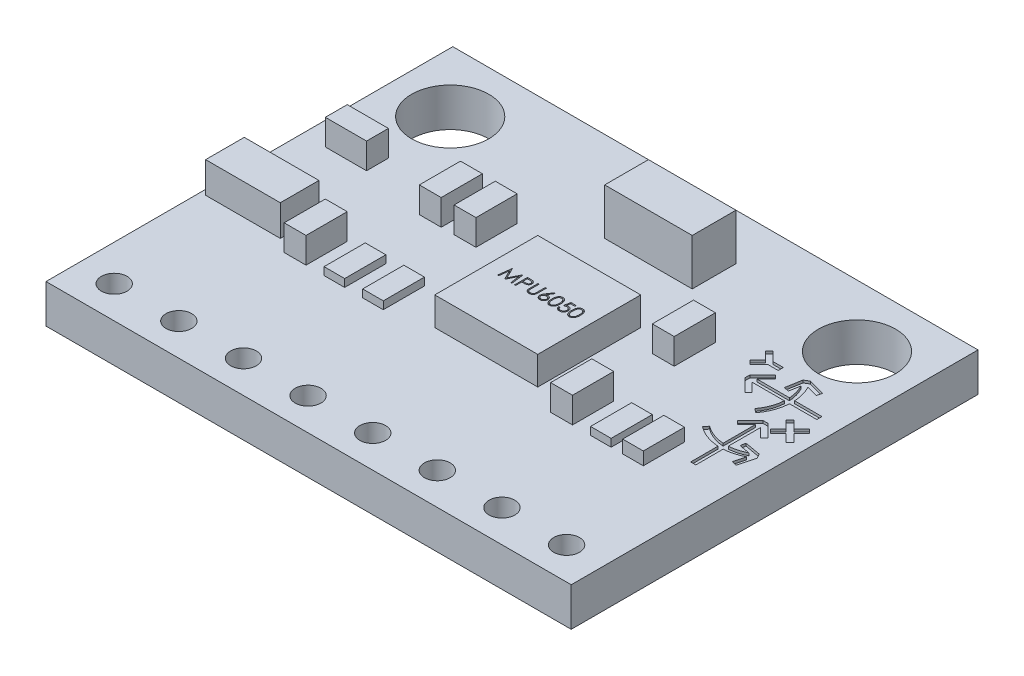
from build123d import *

# Parameters (mm, degrees)
SKETCH1_W           = 20.4
SKETCH1_H           = 15.8
BOSS_EXTRUDE1_DEPTH = 1.5
CUT_EXTRUDE1_REACH  = 3.5
SKETCH2_R           = 1.5
CUT_EXTRUDE2_REACH  = 3.5
SKETCH3_R           = 0.5
SKETCH4_W           = 3.4
SKETCH4_H           = 1.7
BOSS_EXTRUDE2_DEPTH = 1.8
SKETCH5_W           = 4
SKETCH5_H           = 4
BOSS_EXTRUDE3_DEPTH = 1.1
CUT_EXTRUDE3_DEPTH  = 0.1
SKETCH6_W           = 2.9
SKETCH6_H           = 1.5
BOSS_EXTRUDE4_DEPTH = 1.2
SKETCH7_W           = 0.85
SKETCH7_H           = 1.6
SKETCH7_W_2         = 1.6
SKETCH7_H_2         = 0.85
BOSS_EXTRUDE5_DEPTH = 1
SKETCH8_W           = 0.8
SKETCH8_H           = 1.6
BOSS_EXTRUDE6_DEPTH = 0.3
SKETCH10_W          = 0.8
SKETCH10_H          = 1.6
BOSS_EXTRUDE8_DEPTH = 0.5
CUT_EXTRUDE4_DEPTH  = 0.1
SKETCH13_R          = 1
BOSS_EXTRUDE9_DEPTH = 1


with BuildPart() as part:
    # Sketch1 → Boss-Extrude1 (new body)
    with BuildSketch(Plane(origin=(0, 0, 0), x_dir=(1, 0, 0), z_dir=(0, 1, 0))):
        Rectangle(SKETCH1_W, SKETCH1_H)
    extrude(amount=BOSS_EXTRUDE1_DEPTH)

    # Sketch2 → Cut-Extrude1 (cut, up to next)
    with BuildSketch(Plane(origin=(0, 1.5, 0), x_dir=(1, 0, 0), z_dir=(0, 1, 0)), mode=Mode.PRIVATE) as cut_extrude1_sk1:
        with Locations((-7.9, 5.5)):
            Circle(SKETCH2_R)
    cut_extrude1_tool1 = extrude(cut_extrude1_sk1.sketch, amount=-CUT_EXTRUDE1_REACH, mode=Mode.PRIVATE) & part.part
    add(cut_extrude1_tool1.solids().sort_by_distance((-7.9, 1.5, -5.5))[0], mode=Mode.SUBTRACT)
    # Sketch2 → Cut-Extrude1 (cut, up to next)
    with BuildSketch(Plane(origin=(0, 1.5, 0), x_dir=(1, 0, 0), z_dir=(0, 1, 0)), mode=Mode.PRIVATE) as cut_extrude1_sk2:
        with Locations((7.9, 5.5)):
            Circle(SKETCH2_R)
    cut_extrude1_tool2 = extrude(cut_extrude1_sk2.sketch, amount=-CUT_EXTRUDE1_REACH, mode=Mode.PRIVATE) & part.part
    add(cut_extrude1_tool2.solids().sort_by_distance((7.9, 1.5, -5.5))[0], mode=Mode.SUBTRACT)

    # Sketch3 → Cut-Extrude2 (cut, up to next)
    with BuildSketch(Plane(origin=(0, 1.5, 0), x_dir=(1, 0, 0), z_dir=(0, 1, 0)), mode=Mode.PRIVATE) as cut_extrude2_sk1:
        with Locations((-8.8, -6.65)):
            Circle(SKETCH3_R)
    cut_extrude2_tool1 = extrude(cut_extrude2_sk1.sketch, amount=-CUT_EXTRUDE2_REACH, mode=Mode.PRIVATE) & part.part
    add(cut_extrude2_tool1.solids().sort_by_distance((-8.8, 1.5, 6.65))[0], mode=Mode.SUBTRACT)
    # Sketch3 → Cut-Extrude2 (cut, up to next)
    with BuildSketch(Plane(origin=(0, 1.5, 0), x_dir=(1, 0, 0), z_dir=(0, 1, 0)), mode=Mode.PRIVATE) as cut_extrude2_sk2:
        with Locations((-6.29, -6.65)):
            Circle(SKETCH3_R)
    cut_extrude2_tool2 = extrude(cut_extrude2_sk2.sketch, amount=-CUT_EXTRUDE2_REACH, mode=Mode.PRIVATE) & part.part
    add(cut_extrude2_tool2.solids().sort_by_distance((-6.29, 1.5, 6.65))[0], mode=Mode.SUBTRACT)
    # Sketch3 → Cut-Extrude2 (cut, up to next)
    with BuildSketch(Plane(origin=(0, 1.5, 0), x_dir=(1, 0, 0), z_dir=(0, 1, 0)), mode=Mode.PRIVATE) as cut_extrude2_sk3:
        with Locations((-3.78, -6.65)):
            Circle(SKETCH3_R)
    cut_extrude2_tool3 = extrude(cut_extrude2_sk3.sketch, amount=-CUT_EXTRUDE2_REACH, mode=Mode.PRIVATE) & part.part
    add(cut_extrude2_tool3.solids().sort_by_distance((-3.78, 1.5, 6.65))[0], mode=Mode.SUBTRACT)
    # Sketch3 → Cut-Extrude2 (cut, up to next)
    with BuildSketch(Plane(origin=(0, 1.5, 0), x_dir=(1, 0, 0), z_dir=(0, 1, 0)), mode=Mode.PRIVATE) as cut_extrude2_sk4:
        with Locations((-1.27, -6.65)):
            Circle(SKETCH3_R)
    cut_extrude2_tool4 = extrude(cut_extrude2_sk4.sketch, amount=-CUT_EXTRUDE2_REACH, mode=Mode.PRIVATE) & part.part
    add(cut_extrude2_tool4.solids().sort_by_distance((-1.27, 1.5, 6.65))[0], mode=Mode.SUBTRACT)
    # Sketch3 → Cut-Extrude2 (cut, up to next)
    with BuildSketch(Plane(origin=(0, 1.5, 0), x_dir=(1, 0, 0), z_dir=(0, 1, 0)), mode=Mode.PRIVATE) as cut_extrude2_sk5:
        with Locations((1.24, -6.65)):
            Circle(SKETCH3_R)
    cut_extrude2_tool5 = extrude(cut_extrude2_sk5.sketch, amount=-CUT_EXTRUDE2_REACH, mode=Mode.PRIVATE) & part.part
    add(cut_extrude2_tool5.solids().sort_by_distance((1.24, 1.5, 6.65))[0], mode=Mode.SUBTRACT)
    # Sketch3 → Cut-Extrude2 (cut, up to next)
    with BuildSketch(Plane(origin=(0, 1.5, 0), x_dir=(1, 0, 0), z_dir=(0, 1, 0)), mode=Mode.PRIVATE) as cut_extrude2_sk6:
        with Locations((3.75, -6.65)):
            Circle(SKETCH3_R)
    cut_extrude2_tool6 = extrude(cut_extrude2_sk6.sketch, amount=-CUT_EXTRUDE2_REACH, mode=Mode.PRIVATE) & part.part
    add(cut_extrude2_tool6.solids().sort_by_distance((3.75, 1.5, 6.65))[0], mode=Mode.SUBTRACT)
    # Sketch3 → Cut-Extrude2 (cut, up to next)
    with BuildSketch(Plane(origin=(0, 1.5, 0), x_dir=(1, 0, 0), z_dir=(0, 1, 0)), mode=Mode.PRIVATE) as cut_extrude2_sk7:
        with Locations((6.26, -6.65)):
            Circle(SKETCH3_R)
    cut_extrude2_tool7 = extrude(cut_extrude2_sk7.sketch, amount=-CUT_EXTRUDE2_REACH, mode=Mode.PRIVATE) & part.part
    add(cut_extrude2_tool7.solids().sort_by_distance((6.26, 1.5, 6.65))[0], mode=Mode.SUBTRACT)
    # Sketch3 → Cut-Extrude2 (cut, up to next)
    with BuildSketch(Plane(origin=(0, 1.5, 0), x_dir=(1, 0, 0), z_dir=(0, 1, 0)), mode=Mode.PRIVATE) as cut_extrude2_sk8:
        with Locations((8.77, -6.65)):
            Circle(SKETCH3_R)
    cut_extrude2_tool8 = extrude(cut_extrude2_sk8.sketch, amount=-CUT_EXTRUDE2_REACH, mode=Mode.PRIVATE) & part.part
    add(cut_extrude2_tool8.solids().sort_by_distance((8.77, 1.5, 6.65))[0], mode=Mode.SUBTRACT)

    # Sketch4 → Boss-Extrude2 (add)
    with BuildSketch(Plane(origin=(0, 1.5, 0), x_dir=(1, 0, 0), z_dir=(0, 1, 0))):
        with Locations((0.9, 5.25)):
            Rectangle(SKETCH4_W, SKETCH4_H)
    extrude(amount=BOSS_EXTRUDE2_DEPTH)

    # Sketch5 → Boss-Extrude3 (add)
    with BuildSketch(Plane(origin=(0, 1.5, 0), x_dir=(1, 0, 0), z_dir=(0, 1, 0))):
        with Locations((0.9, 0.1)):
            Rectangle(SKETCH5_W, SKETCH5_H)
    extrude(amount=BOSS_EXTRUDE3_DEPTH)

    # Sketch11 → Cut-Extrude3 (cut)
    with BuildSketch(Plane(origin=(0, 2.6, 0), x_dir=(1, 0, 0), z_dir=(0, 1, 0))):
        Polygon((-0.549218035, -0.010882955), (-0.483212426, 0.489117045), (-0.47680217, 0.489117045), (-0.270371881, 0.078860635), (-0.064442394, 0.489117045), (-0.057931977, 0.489117045), (0.008474273, -0.010882955), (-0.036597843, -0.010882955), (-0.084474445, 0.348892686), (-0.264963227, -0.010882955), (-0.275079413, -0.010882955), (-0.456269317, 0.349693968), (-0.504045759, -0.010882955), align=None)
        with BuildLine():
            Line((0.111038375, 0.489117045), (0.209095266, 0.489117045))
            add(Edge.make_bspline(
                [(0.209095266, 0.489117045), (0.215839681, 0.489109631), (0.22876228, 0.489095426), (0.247293003, 0.488664748), (0.264122964, 0.488089506), (0.279215876, 0.487292093), (0.292618175, 0.486349723), (0.304269218, 0.485028003), (0.314260583, 0.483647961), (0.320247219, 0.482244903), (0.322977478, 0.481605026)],
                knots=[0, 0, 0, 0, 2.0233e-05, 3.8767e-05, 5.5604e-05, 7.075e-05, 8.4109e-05, 9.5899e-05, 0.000105928, 0.000114337, 0.000114337, 0.000114337, 0.000114337], degree=3))
            add(Edge.make_bspline(
                [(0.322977478, 0.481605026), (0.326433697, 0.480659033), (0.333264694, 0.478789338), (0.3431077, 0.475044521), (0.352472535, 0.470604211), (0.361391329, 0.465543649), (0.369754484, 0.459645711), (0.377686775, 0.45314948), (0.385118201, 0.44590497), (0.392006971, 0.437993436), (0.398333371, 0.429547691), (0.403780468, 0.420441659), (0.408341501, 0.410828615), (0.412253397, 0.400715248), (0.41506889, 0.39001663), (0.417189876, 0.3788071), (0.418536108, 0.367087858), (0.418665046, 0.359079306), (0.418730683, 0.355002462)],
                knots=[0, 0, 0, 0, 1.0745e-05, 2.1237e-05, 3.1542e-05, 4.1816e-05, 5.1958e-05, 6.2205e-05, 7.2546e-05, 8.3052e-05, 9.3649e-05, 0.000104162, 0.000114824, 0.000125539, 0.000136642, 0.000147957, 0.000159748, 0.000171974, 0.000171974, 0.000171974, 0.000171974], degree=3))
            add(Edge.make_bspline(
                [(0.418730683, 0.355002462), (0.418670479, 0.350891351), (0.418552687, 0.342847684), (0.417138932, 0.331080143), (0.415234619, 0.319834659), (0.412306469, 0.309136166), (0.408471372, 0.299048199), (0.403972508, 0.289416594), (0.398546289, 0.280405212), (0.392311313, 0.271981339), (0.385375371, 0.264137065), (0.377767809, 0.256929238), (0.369519338, 0.250400046), (0.360656174, 0.244534854), (0.35109191, 0.239469672), (0.340971603, 0.234932914), (0.330207286, 0.231122762), (0.322758355, 0.229118468), (0.318971067, 0.228099417)],
                knots=[0, 0, 0, 0, 1.2326e-05, 2.4117e-05, 3.5512e-05, 4.652e-05, 5.7328e-05, 6.7857e-05, 7.8369e-05, 8.8826e-05, 9.9257e-05, 0.000109743, 0.000120223, 0.00013078, 0.000141579, 0.000152654, 0.000164027, 0.00017579, 0.00017579, 0.00017579, 0.00017579], degree=3))
            add(Edge.make_bspline(
                [(0.318971067, 0.228099417), (0.315838591, 0.227433277), (0.308973587, 0.225973392), (0.297667484, 0.224343612), (0.284503858, 0.222952526), (0.269500675, 0.221909507), (0.252671403, 0.221016597), (0.234006937, 0.220306869), (0.21347064, 0.21991689), (0.199146177, 0.219896777), (0.191667382, 0.219886276)],
                knots=[0, 0, 0, 0, 9.605e-06, 2.1051e-05, 3.4247e-05, 4.9311e-05, 6.6162e-05, 8.4805e-05, 0.000105342, 0.000127778, 0.000127778, 0.000127778, 0.000127778], degree=3))
            Line((0.191667382, 0.219886276), (0.15591017, 0.219886276))
            Line((0.15591017, 0.219886276), (0.15591017, -0.010882955))
            Line((0.15591017, -0.010882955), (0.111038375, -0.010882955))
            Line((0.111038375, -0.010882955), (0.111038375, 0.489117045))
        make_face()
        with BuildLine():
            Line((0.15591017, 0.437834994), (0.15591017, 0.271168327))
            Line((0.15591017, 0.271168327), (0.243450234, 0.270066564))
            add(Edge.make_bspline(
                [(0.243450234, 0.270066564), (0.247724509, 0.270064355), (0.255975909, 0.27006009), (0.26789537, 0.270629408), (0.278953839, 0.271286627), (0.28911735, 0.272248902), (0.298390484, 0.273609082), (0.306788702, 0.274982187), (0.314246885, 0.276968667), (0.322975343, 0.279643391), (0.332701535, 0.284205194), (0.343282613, 0.290826607), (0.35224984, 0.299266708), (0.360009597, 0.308756398), (0.366167579, 0.319313416), (0.370675578, 0.330608979), (0.373324315, 0.342527243), (0.373679486, 0.350682691), (0.373858888, 0.354802141)],
                knots=[0, 0, 0, 0, 1.2821e-05, 2.475e-05, 3.579e-05, 4.6056e-05, 5.5362e-05, 6.3909e-05, 7.1561e-05, 7.8498e-05, 9.1272e-05, 0.000103663, 0.000115784, 0.000128032, 0.000140332, 0.000152291, 0.000164394, 0.000176747, 0.000176747, 0.000176747, 0.000176747], degree=3))
            add(Edge.make_bspline(
                [(0.373858888, 0.354802141), (0.37367851, 0.358821929), (0.373319941, 0.366812769), (0.370654817, 0.378524021), (0.366176344, 0.38970055), (0.359968259, 0.400125276), (0.352433812, 0.40958082), (0.343676763, 0.417794695), (0.333717725, 0.424397795), (0.324453692, 0.428659693), (0.316224952, 0.431261875), (0.309077529, 0.433082566), (0.301007432, 0.434536224), (0.292012035, 0.435713296), (0.282161059, 0.436720934), (0.271369871, 0.437404645), (0.259679351, 0.437804853), (0.251563555, 0.437824703), (0.247356484, 0.437834994)],
                knots=[0, 0, 0, 0, 1.2053e-05, 2.396e-05, 3.5826e-05, 4.804e-05, 6.0225e-05, 7.1989e-05, 8.3907e-05, 9.5918e-05, 0.000102443, 0.00010978, 0.00011803, 0.000127025, 0.000136992, 0.000147732, 0.000159457, 0.000172078, 0.000172078, 0.000172078, 0.000172078], degree=3))
            Line((0.247356484, 0.437834994), (0.15591017, 0.437834994))
        make_face(mode=Mode.SUBTRACT)
        with BuildLine():
            Line((0.521294785, 0.489117045), (0.56616658, 0.489117045))
            Line((0.56616658, 0.489117045), (0.56616658, 0.189537718))
            add(Edge.make_bspline(
                [(0.56616658, 0.189537718), (0.566159903, 0.185297613), (0.56614723, 0.177251283), (0.566231875, 0.165798668), (0.566468928, 0.155616889), (0.566618379, 0.146666696), (0.566950855, 0.138989161), (0.567222005, 0.132542688), (0.567570656, 0.127357802), (0.567989673, 0.124331955), (0.568169785, 0.123031308)],
                knots=[0, 0, 0, 0, 1.272e-05, 2.4139e-05, 3.4357e-05, 4.3274e-05, 5.0992e-05, 5.7409e-05, 6.2633e-05, 6.6571e-05, 6.6571e-05, 6.6571e-05, 6.6571e-05], degree=3))
            add(Edge.make_bspline(
                [(0.568169785, 0.123031308), (0.568909422, 0.118338913), (0.57034702, 0.109218523), (0.574010789, 0.096231626), (0.579127575, 0.084527132), (0.585190866, 0.073739804), (0.593181239, 0.064169896), (0.602753173, 0.055353945), (0.614349997, 0.047643688), (0.627244369, 0.040593572), (0.64114226, 0.034927131), (0.65534387, 0.030642365), (0.669635724, 0.028031094), (0.679203748, 0.027728731), (0.683955042, 0.027578583)],
                knots=[0, 0, 0, 0, 1.4244e-05, 2.7686e-05, 4.0338e-05, 5.2501e-05, 6.4671e-05, 7.7574e-05, 9.1409e-05, 0.000106333, 0.000121604, 0.00013634, 0.000150781, 0.000165026, 0.000165026, 0.000165026, 0.000165026], degree=3))
            add(Edge.make_bspline(
                [(0.683955042, 0.027578583), (0.688034148, 0.027731991), (0.696168799, 0.028037919), (0.708255432, 0.029932409), (0.720026876, 0.033346776), (0.731541259, 0.037752455), (0.742334257, 0.04357354), (0.752411891, 0.050297945), (0.761406739, 0.058185213), (0.769615025, 0.066913834), (0.776762873, 0.076762377), (0.78295875, 0.087516397), (0.788033883, 0.099337732), (0.790540101, 0.107645507), (0.791827638, 0.111913519)],
                knots=[0, 0, 0, 0, 1.224e-05, 2.4409e-05, 3.6585e-05, 4.8953e-05, 6.132e-05, 7.3294e-05, 8.5222e-05, 9.7128e-05, 0.000109168, 0.000121641, 0.000134293, 0.00014766, 0.00014766, 0.00014766, 0.00014766], degree=3))
            add(Edge.make_bspline(
                [(0.791827638, 0.111913519), (0.792256227, 0.113677601), (0.793211297, 0.117608687), (0.794103732, 0.124254586), (0.795033236, 0.132095923), (0.795678174, 0.14118904), (0.79630692, 0.151503464), (0.796683073, 0.16309293), (0.796856935, 0.175915353), (0.796908747, 0.184863518), (0.796935811, 0.189537718)],
                knots=[0, 0, 0, 0, 5.443e-06, 1.2129e-05, 2.0093e-05, 2.9134e-05, 3.9468e-05, 5.1094e-05, 6.3916e-05, 7.7939e-05, 7.7939e-05, 7.7939e-05, 7.7939e-05], degree=3))
            Line((0.796935811, 0.189537718), (0.796935811, 0.489117045))
            Line((0.796935811, 0.489117045), (0.841807606, 0.489117045))
            Line((0.841807606, 0.489117045), (0.841807606, 0.187133872))
            add(Edge.make_bspline(
                [(0.841807606, 0.187133872), (0.841771303, 0.181691246), (0.841700456, 0.171069632), (0.841086088, 0.155505152), (0.840106516, 0.14074044), (0.838722504, 0.126773512), (0.836888646, 0.113654346), (0.834849329, 0.101267951), (0.832252253, 0.089703238), (0.82921891, 0.078870035), (0.82575126, 0.068557819), (0.821259667, 0.058770874), (0.816199024, 0.049211674), (0.810196931, 0.040024801), (0.803452448, 0.03116958), (0.795816494, 0.022699712), (0.787541613, 0.014479848), (0.778490248, 0.006720838), (0.768811601, -0.000394687), (0.758534464, -0.006651511), (0.747737783, -0.011940599), (0.736449622, -0.016294303), (0.724665165, -0.019567817), (0.712384113, -0.022007125), (0.699578514, -0.023393168), (0.690869278, -0.023599158), (0.686459048, -0.023703468)],
                knots=[0, 0, 0, 0, 1.6327e-05, 3.1864e-05, 4.6721e-05, 6.0714e-05, 7.3958e-05, 8.6456e-05, 9.8363e-05, 0.000109494, 0.0001202, 0.00013096, 0.000141759, 0.000152622, 0.00016384, 0.000175119, 0.000186806, 0.00019881, 0.00021085, 0.000222806, 0.000234856, 0.000246872, 0.000259048, 0.000271502, 0.000284399, 0.000297629, 0.000297629, 0.000297629, 0.000297629], degree=3))
            add(Edge.make_bspline(
                [(0.686459048, -0.023703468), (0.681649176, -0.023591359), (0.672212225, -0.0233714), (0.658306787, -0.022111008), (0.644976187, -0.019736951), (0.632079634, -0.016714102), (0.619792705, -0.012544997), (0.607950785, -0.007673836), (0.596756688, -0.00169137), (0.586028812, 0.004964829), (0.576053847, 0.012454063), (0.566897075, 0.020616945), (0.558543379, 0.029322713), (0.551133565, 0.038665622), (0.544544868, 0.048573009), (0.538869123, 0.0590729), (0.533995802, 0.070161231), (0.531480578, 0.077868831), (0.530209048, 0.081765282)],
                knots=[0, 0, 0, 0, 1.4432e-05, 2.8315e-05, 4.1834e-05, 5.5025e-05, 6.8011e-05, 8.0716e-05, 9.3396e-05, 0.00010604, 0.00011856, 0.000130763, 0.000142806, 0.00015471, 0.000166489, 0.000178455, 0.000190476, 0.000202766, 0.000202766, 0.000202766, 0.000202766], degree=3))
            add(Edge.make_bspline(
                [(0.530209048, 0.081765282), (0.529469454, 0.084427078), (0.527865258, 0.090200574), (0.526147359, 0.099755787), (0.524703204, 0.110757918), (0.523345267, 0.12320772), (0.522543987, 0.137114844), (0.521841496, 0.152473261), (0.521289836, 0.169301541), (0.52129309, 0.181023615), (0.521294785, 0.187133872)],
                knots=[0, 0, 0, 0, 8.284e-06, 1.7969e-05, 2.9088e-05, 4.1576e-05, 5.5528e-05, 7.0868e-05, 8.7703e-05, 0.000106032, 0.000106032, 0.000106032, 0.000106032], degree=3))
            Line((0.521294785, 0.187133872), (0.521294785, 0.489117045))
        make_face()
        with BuildLine():
            Line((1.15591017, 0.501937558), (1.190465458, 0.474794128))
            Line((1.190465458, 0.474794128), (1.05835408, 0.272770891))
            add(Edge.make_bspline(
                [(1.05835408, 0.272770891), (1.067149834, 0.274172871), (1.084306946, 0.276907592), (1.101673503, 0.277358727), (1.110136933, 0.277578583)],
                knots=[0, 0, 0, 0, 2.6687e-05, 5.2056e-05, 5.2056e-05, 5.2056e-05, 5.2056e-05], degree=3))
            add(Edge.make_bspline(
                [(1.110136933, 0.277578583), (1.115218718, 0.277441996), (1.125222061, 0.277173128), (1.139908747, 0.275104006), (1.154021452, 0.271843276), (1.167501682, 0.267090097), (1.180397823, 0.261018332), (1.192783879, 0.25374135), (1.204427024, 0.244883396), (1.215477192, 0.234988402), (1.225509635, 0.224028833), (1.234391928, 0.212400071), (1.241852898, 0.20011423), (1.247906316, 0.187177535), (1.252607013, 0.173609927), (1.256033819, 0.159428764), (1.258059475, 0.144624268), (1.258334545, 0.134555957), (1.258474273, 0.129441564)],
                knots=[0, 0, 0, 0, 1.524e-05, 3e-05, 4.4407e-05, 5.863e-05, 7.2789e-05, 8.7115e-05, 0.000101639, 0.000116603, 0.00013156, 0.000146144, 0.000160436, 0.000174595, 0.000188912, 0.00020344, 0.000218299, 0.00023364, 0.00023364, 0.00023364, 0.00023364], degree=3))
            add(Edge.make_bspline(
                [(1.258474273, 0.129441564), (1.258270972, 0.122444464), (1.257870924, 0.108675826), (1.253884668, 0.08862201), (1.247690433, 0.069517365), (1.2388365, 0.051666912), (1.227839017, 0.035095117), (1.214427932, 0.020411479), (1.199078862, 0.007315759), (1.181723605, -0.003635187), (1.163046039, -0.01257848), (1.143424325, -0.019002086), (1.123049019, -0.022956867), (1.109219789, -0.023452667), (1.102224273, -0.023703468)],
                knots=[0, 0, 0, 0, 2.0968e-05, 4.126e-05, 6.1088e-05, 8.1066e-05, 0.000100845, 0.000120559, 0.000140527, 0.000161199, 0.000181942, 0.000202498, 0.000222987, 0.000243961, 0.000243961, 0.000243961, 0.000243961], degree=3))
            add(Edge.make_bspline(
                [(1.102224273, -0.023703468), (1.095496172, -0.023485153), (1.082168984, -0.023052709), (1.062564299, -0.019200432), (1.043726725, -0.01295656), (1.025788242, -0.00435452), (1.009171012, 0.006510892), (0.994304492, 0.019591217), (0.98126281, 0.034606855), (0.970409293, 0.051555476), (0.961800903, 0.069768327), (0.955345199, 0.088759349), (0.951574307, 0.108459347), (0.951047371, 0.121813795), (0.950781965, 0.128540122)],
                knots=[0, 0, 0, 0, 2.0168e-05, 3.9949e-05, 5.9682e-05, 7.9573e-05, 9.9463e-05, 0.000119052, 0.000138792, 0.000158934, 0.00017923, 0.000199089, 0.000218969, 0.000239143, 0.000239143, 0.000239143, 0.000239143], degree=3))
            add(Edge.make_bspline(
                [(0.950781965, 0.128540122), (0.950950743, 0.133689348), (0.951295355, 0.144203084), (0.953701553, 0.160126517), (0.957567953, 0.176419528), (0.961897988, 0.190241556), (0.966473075, 0.20156463), (0.970280581, 0.210693701), (0.975019723, 0.22008814), (0.980073063, 0.230070088), (0.985895473, 0.240382292), (0.99222628, 0.251197102), (0.999240516, 0.26234252), (1.004157682, 0.269905977), (1.006671388, 0.273772494)],
                knots=[0, 0, 0, 0, 1.5445e-05, 3.1537e-05, 4.8203e-05, 6.5657e-05, 7.4919e-05, 8.4835e-05, 9.5317e-05, 0.000106472, 0.000118399, 0.000130836, 0.000144064, 0.0001579, 0.0001579, 0.0001579, 0.0001579], degree=3))
            Line((1.006671388, 0.273772494), (1.15591017, 0.501937558))
        make_face()
        with BuildLine():
            add(Edge.make_bspline(
                [(1.100721869, 0.226296532), (1.096912977, 0.226185383), (1.089473104, 0.225968277), (1.078557759, 0.224707526), (1.068227294, 0.222333374), (1.058344847, 0.219309612), (1.049095175, 0.215152032), (1.040411055, 0.210101775), (1.032258905, 0.204155893), (1.024724112, 0.19739862), (1.017892731, 0.190000329), (1.012009712, 0.182076112), (1.006935084, 0.17381694), (1.00280911, 0.165153805), (0.999596242, 0.15609002), (0.997272206, 0.14666727), (0.995978813, 0.136822369), (0.995763637, 0.130146297), (0.99565376, 0.126737237)],
                knots=[0, 0, 0, 0, 1.1429e-05, 2.2325e-05, 3.2895e-05, 4.319e-05, 5.3279e-05, 6.3243e-05, 7.328e-05, 8.3494e-05, 9.356e-05, 0.000103436, 0.000113055, 0.000122598, 0.000132165, 0.000141858, 0.00015166, 0.000161889, 0.000161889, 0.000161889, 0.000161889], degree=3))
            add(Edge.make_bspline(
                [(0.99565376, 0.126737237), (0.99574324, 0.123358669), (0.995918697, 0.116733799), (0.997511886, 0.106971059), (0.999945469, 0.097576072), (1.003565526, 0.088597272), (1.007883652, 0.079897798), (1.013584413, 0.071792757), (1.019901097, 0.06378989), (1.027451659, 0.056503966), (1.035554996, 0.049724448), (1.044212311, 0.043798697), (1.053235162, 0.038729244), (1.062745365, 0.03475623), (1.072607992, 0.031495618), (1.082905214, 0.029201121), (1.093644193, 0.027903903), (1.100918756, 0.027688446), (1.104628119, 0.027578583)],
                knots=[0, 0, 0, 0, 1.0129e-05, 1.9861e-05, 2.9603e-05, 3.9182e-05, 4.8857e-05, 5.8664e-05, 6.8847e-05, 7.94e-05, 9.007e-05, 0.000100516, 0.000110828, 0.00012106, 0.000131386, 0.000141957, 0.000152653, 0.000163782, 0.000163782, 0.000163782, 0.000163782], degree=3))
            add(Edge.make_bspline(
                [(1.104628119, 0.027578583), (1.108337476, 0.027688455), (1.115612026, 0.027903928), (1.126351092, 0.029201024), (1.136647995, 0.031495973), (1.146511782, 0.034754941), (1.1560177, 0.038734028), (1.165032661, 0.043767159), (1.173608103, 0.04976089), (1.18171676, 0.05649238), (1.189235894, 0.063831359), (1.195704076, 0.071721319), (1.201230253, 0.079963304), (1.205720851, 0.088563003), (1.209301035, 0.097581501), (1.211746959, 0.106969604), (1.213336857, 0.116734179), (1.213512767, 0.123358797), (1.213602478, 0.126737237)],
                knots=[0, 0, 0, 0, 1.1129e-05, 2.1826e-05, 3.2396e-05, 4.2722e-05, 5.2954e-05, 6.3266e-05, 7.363e-05, 8.4299e-05, 9.4852e-05, 0.000105099, 0.00011485, 0.000124572, 0.00013415, 0.000143893, 0.000153625, 0.000163753, 0.000163753, 0.000163753, 0.000163753], degree=3))
            add(Edge.make_bspline(
                [(1.213602478, 0.126737237), (1.213523864, 0.130150745), (1.213369572, 0.136850349), (1.211624437, 0.146662866), (1.209204097, 0.156137896), (1.205549379, 0.165215888), (1.200801301, 0.173861021), (1.195017957, 0.182116964), (1.18832759, 0.190047013), (1.18059937, 0.197413129), (1.172186479, 0.204148426), (1.163241396, 0.210094077), (1.153883114, 0.21511193), (1.144121122, 0.219298659), (1.133843567, 0.222320013), (1.123216376, 0.224699047), (1.112103627, 0.22596505), (1.104564112, 0.226184631), (1.100721869, 0.226296532)],
                knots=[0, 0, 0, 0, 1.0229e-05, 2.0075e-05, 2.9818e-05, 3.9527e-05, 4.9343e-05, 5.9345e-05, 6.9721e-05, 8.0417e-05, 9.132e-05, 0.000102015, 0.000112591, 0.000123139, 0.000133816, 0.00014468, 0.000155775, 0.000167304, 0.000167304, 0.000167304, 0.000167304], degree=3))
        make_face(mode=Mode.SUBTRACT)
        with BuildLine():
            add(Edge.make_bspline(
                [(1.309756324, 0.238916724), (1.309803184, 0.246930637), (1.309894209, 0.262497778), (1.310906841, 0.285181298), (1.312589033, 0.306461339), (1.314894372, 0.32633892), (1.317699797, 0.344819172), (1.321444867, 0.361852709), (1.325703839, 0.377518367), (1.330639902, 0.391867231), (1.336209586, 0.405092617), (1.342271624, 0.417439074), (1.349066594, 0.428887922), (1.356206153, 0.439621892), (1.363979306, 0.449465277), (1.372164848, 0.458557086), (1.381082259, 0.466687193), (1.390428403, 0.474093808), (1.400287898, 0.480586589), (1.410379707, 0.486305552), (1.420773294, 0.491191247), (1.431497034, 0.495032738), (1.442454542, 0.498205716), (1.453684123, 0.500375566), (1.465204318, 0.501740839), (1.472980238, 0.501871363), (1.476923792, 0.501937558)],
                knots=[0, 0, 0, 0, 2.404e-05, 4.6699e-05, 6.8101e-05, 8.8066e-05, 0.000106723, 0.000124149, 0.000140356, 0.000155402, 0.000169633, 0.000183384, 0.000196628, 0.000209546, 0.000222029, 0.000234224, 0.000246203, 0.000258186, 0.000269964, 0.00028158, 0.000292962, 0.000304369, 0.000315719, 0.000327152, 0.000338644, 0.00035047, 0.00035047, 0.00035047, 0.00035047], degree=3))
            add(Edge.make_bspline(
                [(1.476923792, 0.501937558), (1.480900289, 0.50186787), (1.48880829, 0.501729283), (1.500499772, 0.500397291), (1.511921155, 0.49818713), (1.523023747, 0.495055563), (1.533898745, 0.491170466), (1.544461089, 0.486300878), (1.554776386, 0.480632468), (1.564680713, 0.473971914), (1.574282801, 0.466545875), (1.583346795, 0.458151208), (1.591873522, 0.448872676), (1.599969994, 0.438809553), (1.607406508, 0.427768827), (1.614488427, 0.415942525), (1.620827289, 0.40312383), (1.626932243, 0.389526621), (1.632201812, 0.374774669), (1.636954133, 0.358951132), (1.640793986, 0.341869105), (1.643992453, 0.323618213), (1.646470295, 0.30413143), (1.648274959, 0.283450528), (1.649228256, 0.2615619), (1.649407785, 0.246596493), (1.649499914, 0.238916724)],
                knots=[0, 0, 0, 0, 1.1926e-05, 2.3717e-05, 3.5247e-05, 4.6791e-05, 5.8292e-05, 6.9855e-05, 8.1646e-05, 9.3563e-05, 0.000105625, 0.000118029, 0.000130574, 0.000143401, 0.000156736, 0.000170478, 0.000184722, 0.000199611, 0.000215168, 0.000231679, 0.000249148, 0.000267657, 0.000287249, 0.00030806, 0.000329918, 0.000352958, 0.000352958, 0.000352958, 0.000352958], degree=3))
            add(Edge.make_bspline(
                [(1.649499914, 0.238916724), (1.64940683, 0.231270452), (1.649225461, 0.216372002), (1.648285645, 0.194581862), (1.646434412, 0.174010713), (1.6441187, 0.154609219), (1.640911419, 0.13645813), (1.636967824, 0.119494638), (1.632589207, 0.103645484), (1.627184236, 0.089040511), (1.62126842, 0.07547598), (1.614831964, 0.062809244), (1.607936274, 0.050928345), (1.600423596, 0.039928381), (1.592415966, 0.02973143), (1.583741996, 0.020517484), (1.574646198, 0.012064531), (1.565015853, 0.00454287), (1.55495706, -0.002040674), (1.544677192, -0.007928366), (1.533993851, -0.012675894), (1.523149144, -0.016752329), (1.511987949, -0.019866679), (1.500524179, -0.022020087), (1.488816145, -0.023530351), (1.480901636, -0.023645562), (1.476923792, -0.023703468)],
                knots=[0, 0, 0, 0, 2.294e-05, 4.4698e-05, 6.541e-05, 8.4889e-05, 0.0001033, 0.000120672, 0.000137126, 0.000152589, 0.000167346, 0.000181501, 0.000195192, 0.000208527, 0.000221432, 0.000234046, 0.00024645, 0.000258652, 0.000270653, 0.000282492, 0.000294147, 0.000305682, 0.000317226, 0.000328855, 0.000340657, 0.000352583, 0.000352583, 0.000352583, 0.000352583], degree=3))
            add(Edge.make_bspline(
                [(1.476923792, -0.023703468), (1.472980347, -0.023636846), (1.465204643, -0.02350548), (1.453682868, -0.022146375), (1.442499662, -0.019961303), (1.43159984, -0.016901788), (1.420927481, -0.013156812), (1.410628011, -0.008277714), (1.400586914, -0.002658561), (1.390830977, 0.003740784), (1.381543525, 0.011072453), (1.372672296, 0.019181638), (1.364440151, 0.028270696), (1.356778137, 0.038196114), (1.349496124, 0.048866577), (1.342797642, 0.060427773), (1.336601806, 0.07283386), (1.33093845, 0.086164991), (1.325917213, 0.100615695), (1.321481826, 0.116351291), (1.317979803, 0.133510668), (1.314982238, 0.151956006), (1.312564469, 0.171766568), (1.310913851, 0.192953107), (1.309893663, 0.215502423), (1.309802939, 0.230969534), (1.309756324, 0.238916724)],
                knots=[0, 0, 0, 0, 1.1826e-05, 2.3318e-05, 3.475e-05, 4.5977e-05, 5.7256e-05, 6.8638e-05, 8.0117e-05, 9.1757e-05, 0.000103599, 0.000115578, 0.000127773, 0.000140335, 0.00015317, 0.0001665, 0.000180386, 0.000194748, 0.000209921, 0.000226252, 0.000243755, 0.000262428, 0.000282305, 0.000303608, 0.000326166, 0.000350006, 0.000350006, 0.000350006, 0.000350006], degree=3))
        make_face()
        with BuildLine():
            add(Edge.make_bspline(
                [(1.354628119, 0.239117045), (1.354645183, 0.232438659), (1.3546783, 0.219477224), (1.355543472, 0.200642473), (1.356722076, 0.183075283), (1.358242262, 0.166753349), (1.360499826, 0.151731919), (1.363029367, 0.137907678), (1.366107665, 0.125353787), (1.369749811, 0.1139841), (1.373898253, 0.103605662), (1.378427662, 0.093948345), (1.38329348, 0.084898069), (1.388739073, 0.076536125), (1.394669796, 0.068835244), (1.40095169, 0.061659125), (1.407819202, 0.055259556), (1.417319737, 0.047584291), (1.42986209, 0.039652987), (1.445665013, 0.032746402), (1.461903363, 0.028406051), (1.47292497, 0.027854086), (1.478426196, 0.027578583)],
                knots=[0, 0, 0, 0, 2.0033e-05, 3.888e-05, 5.6549e-05, 7.2854e-05, 8.8039e-05, 0.000102104, 0.000115004, 0.000126787, 0.000137891, 0.00014851, 0.000158774, 0.000168692, 0.000178408, 0.000187915, 0.000197268, 0.000206529, 0.000224535, 0.00024158, 0.000258123, 0.000274609, 0.000274609, 0.000274609, 0.000274609], degree=3))
            add(Edge.make_bspline(
                [(1.478426196, 0.027578583), (1.483963006, 0.027806838), (1.495025195, 0.028262875), (1.511187166, 0.032662695), (1.526877204, 0.039301201), (1.539173196, 0.047150844), (1.548527845, 0.05462632), (1.555230272, 0.060999841), (1.561381993, 0.068136394), (1.567216575, 0.075836293), (1.572567872, 0.084246648), (1.577434034, 0.093327016), (1.581874513, 0.103102613), (1.584404376, 0.109926861), (1.58569783, 0.113415923)],
                knots=[0, 0, 0, 0, 1.6578e-05, 3.3121e-05, 4.9903e-05, 6.7548e-05, 7.6668e-05, 8.5806e-05, 9.5248e-05, 0.000104903, 0.000114767, 0.000125119, 0.000135787, 0.000146948, 0.000146948, 0.000146948, 0.000146948], degree=3))
            add(Edge.make_bspline(
                [(1.58569783, 0.113415923), (1.587205226, 0.117877314), (1.590265885, 0.126935852), (1.594210424, 0.140987803), (1.59731691, 0.155731055), (1.600111676, 0.1710775), (1.602019255, 0.187140314), (1.603554657, 0.203869798), (1.604459041, 0.221278564), (1.604571149, 0.23310642), (1.604628119, 0.239117045)],
                knots=[0, 0, 0, 0, 1.4127e-05, 2.8683e-05, 4.3751e-05, 5.9313e-05, 7.5463e-05, 9.2257e-05, 0.000109708, 0.00012774, 0.00012774, 0.00012774, 0.00012774], degree=3))
            add(Edge.make_bspline(
                [(1.604628119, 0.239117045), (1.60454952, 0.245126698), (1.604395765, 0.256882865), (1.603808052, 0.274099747), (1.602290399, 0.290452285), (1.60060481, 0.306010924), (1.598119493, 0.320689538), (1.595439806, 0.334611011), (1.591839633, 0.347602871), (1.587993951, 0.359868526), (1.583592466, 0.371268619), (1.578747361, 0.381856303), (1.573572824, 0.391682692), (1.567952504, 0.400720827), (1.561953121, 0.40901119), (1.555416328, 0.416387561), (1.548601418, 0.423078556), (1.539056105, 0.430716066), (1.526559778, 0.438503451), (1.5110104, 0.445669988), (1.494828879, 0.449785459), (1.483889815, 0.4503657), (1.478426196, 0.450655506)],
                knots=[0, 0, 0, 0, 1.8031e-05, 3.5273e-05, 5.1659e-05, 6.7289e-05, 8.2207e-05, 9.6311e-05, 0.000109795, 0.000122624, 0.000134863, 0.000146427, 0.000157539, 0.000168156, 0.000178333, 0.000188198, 0.000197689, 0.00020695, 0.000224818, 0.00024172, 0.000258142, 0.000274528, 0.000274528, 0.000274528, 0.000274528], degree=3))
            add(Edge.make_bspline(
                [(1.478426196, 0.450655506), (1.472896111, 0.4503653), (1.461825867, 0.449784358), (1.44547616, 0.445685322), (1.429804109, 0.438540612), (1.417340827, 0.430690273), (1.407788858, 0.423213372), (1.401062759, 0.416729592), (1.394756163, 0.40963727), (1.388946491, 0.401865568), (1.383505165, 0.393513373), (1.378507878, 0.384514978), (1.374005402, 0.374824783), (1.369850468, 0.364451007), (1.366197213, 0.3530823), (1.363183789, 0.340543873), (1.360399925, 0.326763602), (1.358429172, 0.311660815), (1.356677207, 0.295334794), (1.3555513, 0.277723748), (1.354675406, 0.258857408), (1.354644197, 0.245828957), (1.354628119, 0.239117045)],
                knots=[0, 0, 0, 0, 1.6586e-05, 3.3202e-05, 5.0195e-05, 6.8064e-05, 7.7262e-05, 8.6542e-05, 9.6049e-05, 0.000105705, 0.000115623, 0.000125935, 0.000136554, 0.000147658, 0.000159441, 0.000172341, 0.000186327, 0.000201596, 0.000218011, 0.00023558, 0.000254527, 0.000274661, 0.000274661, 0.000274661, 0.000274661], degree=3))
        make_face(mode=Mode.SUBTRACT)
        with BuildLine():
            Line((2.008474273, 0.489117045), (2.008474273, 0.437834994))
            Line((2.008474273, 0.437834994), (1.838402157, 0.437834994))
            Line((1.838402157, 0.437834994), (1.811459048, 0.306324577))
            add(Edge.make_bspline(
                [(1.811459048, 0.306324577), (1.816752745, 0.307786044), (1.827008444, 0.310617406), (1.842145567, 0.313761088), (1.856515882, 0.315656151), (1.865840935, 0.31591491), (1.870353279, 0.316040122)],
                knots=[0, 0, 0, 0, 1.6472e-05, 3.1911e-05, 4.6347e-05, 5.9882e-05, 5.9882e-05, 5.9882e-05, 5.9882e-05], degree=3))
            add(Edge.make_bspline(
                [(1.870353279, 0.316040122), (1.87593667, 0.315919274), (1.886915013, 0.315681657), (1.90297772, 0.313399964), (1.91831099, 0.309808547), (1.932882757, 0.30479133), (1.946719979, 0.298375654), (1.959695345, 0.290361377), (1.972003618, 0.280999472), (1.983423988, 0.270235899), (1.993784604, 0.258389954), (2.002894031, 0.245653115), (2.010631544, 0.232149163), (2.016854509, 0.217749076), (2.0218237, 0.202612055), (2.025131127, 0.186578828), (2.027333514, 0.169800526), (2.02757957, 0.158328444), (2.027705042, 0.152478423)],
                knots=[0, 0, 0, 0, 1.6741e-05, 3.2918e-05, 4.8563e-05, 6.3926e-05, 7.9071e-05, 9.4222e-05, 0.000109587, 0.000125389, 0.000141218, 0.000156727, 0.000172294, 0.000187813, 0.000203714, 0.000219999, 0.000236858, 0.0002544, 0.0002544, 0.0002544, 0.0002544], degree=3))
            add(Edge.make_bspline(
                [(2.027705042, 0.152478423), (2.027610031, 0.14840382), (2.027421294, 0.140309679), (2.026461495, 0.128289079), (2.024613536, 0.11652296), (2.022132432, 0.105009761), (2.018912087, 0.093771279), (2.015013651, 0.082775347), (2.01024279, 0.072090403), (2.005009736, 0.061615347), (1.999117382, 0.051586988), (1.992577595, 0.042208562), (1.985668239, 0.033339379), (1.978233756, 0.02507456), (1.970205042, 0.017468414), (1.961679333, 0.010475803), (1.952724658, 0.00397847), (1.943202481, -0.001759844), (1.933324983, -0.007040266), (1.922949524, -0.0113722), (1.912312281, -0.015245133), (1.901260156, -0.018332208), (1.889818183, -0.020751144), (1.8779675, -0.022394087), (1.865770262, -0.023590721), (1.857502403, -0.023665629), (1.853326035, -0.023703468)],
                knots=[0, 0, 0, 0, 1.2226e-05, 2.4287e-05, 3.6144e-05, 4.7931e-05, 5.9598e-05, 7.1193e-05, 8.2899e-05, 9.4679e-05, 0.000106309, 0.000117755, 0.000128956, 0.000140019, 0.000151071, 0.0001621, 0.00017308, 0.000184228, 0.000195429, 0.000206647, 0.000217926, 0.000229373, 0.000241041, 0.000252982, 0.000265251, 0.000277775, 0.000277775, 0.000277775, 0.000277775], degree=3))
            add(Edge.make_bspline(
                [(1.853326035, -0.023703468), (1.84834401, -0.023604777), (1.838542462, -0.023410614), (1.824182381, -0.021379401), (1.810366009, -0.01847027), (1.797204566, -0.014093661), (1.7845801, -0.008609761), (1.772662569, -0.00167888), (1.761147458, 0.006175278), (1.750502881, 0.0154439), (1.740623436, 0.025574712), (1.731779649, 0.03656866), (1.723903424, 0.048244295), (1.717120889, 0.060658317), (1.711335457, 0.073778107), (1.706790459, 0.087652821), (1.703122122, 0.102209965), (1.701570205, 0.112231895), (1.700781965, 0.117322173)],
                knots=[0, 0, 0, 0, 1.4936e-05, 2.9385e-05, 4.3432e-05, 5.7242e-05, 7.092e-05, 8.4648e-05, 9.854e-05, 0.000112674, 0.000126911, 0.000140942, 0.000154943, 0.000169108, 0.000183326, 0.000197895, 0.00021286, 0.000228305, 0.000228305, 0.000228305, 0.000228305], degree=3))
            Line((1.700781965, 0.117322173), (1.74565376, 0.117322173))
            add(Edge.make_bspline(
                [(1.74565376, 0.117322173), (1.746757839, 0.112554109), (1.748879942, 0.103389624), (1.753537906, 0.090513718), (1.759233031, 0.079039543), (1.766005081, 0.068815317), (1.774083656, 0.059899746), (1.783302146, 0.051954451), (1.793637535, 0.044786575), (1.805122282, 0.038811894), (1.817238437, 0.033716358), (1.829919467, 0.030323259), (1.842820088, 0.027937417), (1.851545569, 0.027698594), (1.855930202, 0.027578583)],
                knots=[0, 0, 0, 0, 1.4673e-05, 2.8202e-05, 4.0968e-05, 5.3024e-05, 6.4869e-05, 7.6939e-05, 8.9469e-05, 0.000102507, 0.000115713, 0.000128811, 0.00014182, 0.00015496, 0.00015496, 0.00015496, 0.00015496], degree=3))
            add(Edge.make_bspline(
                [(1.855930202, 0.027578583), (1.86020998, 0.027695837), (1.868636897, 0.027926711), (1.881038524, 0.029703713), (1.893011792, 0.032440509), (1.904438557, 0.036536203), (1.915518777, 0.04151402), (1.925972173, 0.047901888), (1.936101155, 0.055253319), (1.945590888, 0.063675694), (1.954282238, 0.072957079), (1.961961684, 0.082882421), (1.968358386, 0.093470542), (1.973748973, 0.104538136), (1.977842302, 0.116206501), (1.980762442, 0.128420954), (1.982477164, 0.141211666), (1.982713047, 0.149935853), (1.982833247, 0.154381468)],
                knots=[0, 0, 0, 0, 1.2835e-05, 2.5271e-05, 3.7516e-05, 4.9617e-05, 6.1628e-05, 7.3893e-05, 8.6294e-05, 9.9136e-05, 0.000111892, 0.000124393, 0.000136709, 0.000148939, 0.000161262, 0.000173724, 0.000186558, 0.000199893, 0.000199893, 0.000199893, 0.000199893], degree=3))
            add(Edge.make_bspline(
                [(1.982833247, 0.154381468), (1.982739178, 0.15839229), (1.982555053, 0.166242902), (1.981050686, 0.177728503), (1.978433975, 0.188596081), (1.974801992, 0.198898114), (1.970190634, 0.20864432), (1.964555447, 0.217844757), (1.957790675, 0.226378162), (1.950063263, 0.234248527), (1.941597828, 0.241512081), (1.932248722, 0.247704093), (1.92221159, 0.252913224), (1.911607361, 0.257408652), (1.900183804, 0.26063733), (1.888167143, 0.263061314), (1.875427613, 0.264463509), (1.866717515, 0.264658064), (1.862240298, 0.264758071)],
                knots=[0, 0, 0, 0, 1.203e-05, 2.3546e-05, 3.4673e-05, 4.5507e-05, 5.6259e-05, 6.6962e-05, 7.7802e-05, 8.8851e-05, 0.000100009, 0.000111204, 0.000122404, 0.0001339, 0.000145691, 0.000157948, 0.000170646, 0.000184077, 0.000184077, 0.000184077, 0.000184077], degree=3))
            add(Edge.make_bspline(
                [(1.862240298, 0.264758071), (1.858364737, 0.264675129), (1.850362686, 0.264503876), (1.838087997, 0.263242948), (1.825189179, 0.261208763), (1.81171568, 0.258410727), (1.797627036, 0.254749145), (1.782952978, 0.250361359), (1.767662655, 0.245115359), (1.757360123, 0.241153614), (1.752064016, 0.239117045)],
                knots=[0, 0, 0, 0, 1.1625e-05, 2.4004e-05, 3.698e-05, 5.0789e-05, 6.5268e-05, 8.0637e-05, 9.6727e-05, 0.000113749, 0.000113749, 0.000113749, 0.000113749], degree=3))
            Line((1.752064016, 0.239117045), (1.803346067, 0.489117045))
            Line((1.803346067, 0.489117045), (2.008474273, 0.489117045))
        make_face()
        with BuildLine():
            add(Edge.make_bspline(
                [(2.078987093, 0.238916724), (2.079033953, 0.246930637), (2.079124979, 0.262497778), (2.08013761, 0.285181298), (2.081819802, 0.306461339), (2.084125141, 0.32633892), (2.086930567, 0.344819172), (2.090675636, 0.361852709), (2.094934608, 0.377518367), (2.099870672, 0.391867231), (2.105440356, 0.405092617), (2.111502393, 0.417439074), (2.118297364, 0.428887922), (2.125436923, 0.439621892), (2.133210076, 0.449465277), (2.141395617, 0.458557086), (2.150313028, 0.466687193), (2.159659172, 0.474093808), (2.169518667, 0.480586589), (2.179610476, 0.486305552), (2.190004063, 0.491191247), (2.200727803, 0.495032738), (2.211685312, 0.498205716), (2.222914893, 0.500375566), (2.234435088, 0.501740839), (2.242211007, 0.501871363), (2.246154561, 0.501937558)],
                knots=[0, 0, 0, 0, 2.404e-05, 4.6699e-05, 6.8101e-05, 8.8066e-05, 0.000106723, 0.000124149, 0.000140356, 0.000155402, 0.000169633, 0.000183384, 0.000196628, 0.000209546, 0.000222029, 0.000234224, 0.000246203, 0.000258186, 0.000269964, 0.00028158, 0.000292962, 0.000304369, 0.000315719, 0.000327152, 0.000338644, 0.00035047, 0.00035047, 0.00035047, 0.00035047], degree=3))
            add(Edge.make_bspline(
                [(2.246154561, 0.501937558), (2.250131058, 0.50186787), (2.258039059, 0.501729283), (2.269730541, 0.500397291), (2.281151924, 0.49818713), (2.292254516, 0.495055563), (2.303129514, 0.491170466), (2.313691858, 0.486300878), (2.324007155, 0.480632468), (2.333911482, 0.473971914), (2.34351357, 0.466545875), (2.352577565, 0.458151208), (2.361104291, 0.448872676), (2.369200763, 0.438809553), (2.376637277, 0.427768827), (2.383719196, 0.415942525), (2.390058058, 0.40312383), (2.396163012, 0.389526621), (2.401432581, 0.374774669), (2.406184902, 0.358951132), (2.410024755, 0.341869105), (2.413223222, 0.323618213), (2.415701065, 0.30413143), (2.417505728, 0.283450528), (2.418459026, 0.2615619), (2.418638554, 0.246596493), (2.418730683, 0.238916724)],
                knots=[0, 0, 0, 0, 1.1926e-05, 2.3717e-05, 3.5247e-05, 4.6791e-05, 5.8292e-05, 6.9855e-05, 8.1646e-05, 9.3563e-05, 0.000105625, 0.000118029, 0.000130574, 0.000143401, 0.000156736, 0.000170478, 0.000184722, 0.000199611, 0.000215168, 0.000231679, 0.000249148, 0.000267657, 0.000287249, 0.00030806, 0.000329918, 0.000352958, 0.000352958, 0.000352958, 0.000352958], degree=3))
            add(Edge.make_bspline(
                [(2.418730683, 0.238916724), (2.418637599, 0.231270452), (2.41845623, 0.216372002), (2.417516415, 0.194581862), (2.415665182, 0.174010713), (2.413349469, 0.154609219), (2.410142189, 0.13645813), (2.406198593, 0.119494638), (2.401819976, 0.103645484), (2.396415005, 0.089040511), (2.390499189, 0.07547598), (2.384062733, 0.062809244), (2.377167043, 0.050928345), (2.369654366, 0.039928381), (2.361646735, 0.02973143), (2.352972765, 0.020517484), (2.343876967, 0.012064531), (2.334246622, 0.00454287), (2.324187829, -0.002040674), (2.313907961, -0.007928366), (2.303224621, -0.012675894), (2.292379913, -0.016752329), (2.281218718, -0.019866679), (2.269754948, -0.022020087), (2.258046914, -0.023530351), (2.250132405, -0.023645562), (2.246154561, -0.023703468)],
                knots=[0, 0, 0, 0, 2.294e-05, 4.4698e-05, 6.541e-05, 8.4889e-05, 0.0001033, 0.000120672, 0.000137126, 0.000152589, 0.000167346, 0.000181501, 0.000195192, 0.000208527, 0.000221432, 0.000234046, 0.00024645, 0.000258652, 0.000270653, 0.000282492, 0.000294147, 0.000305682, 0.000317226, 0.000328855, 0.000340657, 0.000352583, 0.000352583, 0.000352583, 0.000352583], degree=3))
            add(Edge.make_bspline(
                [(2.246154561, -0.023703468), (2.242211116, -0.023636846), (2.234435413, -0.02350548), (2.222913638, -0.022146375), (2.211730431, -0.019961303), (2.200830609, -0.016901788), (2.19015825, -0.013156812), (2.179858781, -0.008277714), (2.169817683, -0.002658561), (2.160061746, 0.003740784), (2.150774295, 0.011072453), (2.141903065, 0.019181638), (2.13367092, 0.028270696), (2.126008906, 0.038196114), (2.118726894, 0.048866577), (2.112028412, 0.060427773), (2.105832575, 0.07283386), (2.10016922, 0.086164991), (2.095147982, 0.100615695), (2.090712595, 0.116351291), (2.087210573, 0.133510668), (2.084213007, 0.151956006), (2.081795238, 0.171766568), (2.080144621, 0.192953107), (2.079124433, 0.215502423), (2.079033708, 0.230969534), (2.078987093, 0.238916724)],
                knots=[0, 0, 0, 0, 1.1826e-05, 2.3318e-05, 3.475e-05, 4.5977e-05, 5.7256e-05, 6.8638e-05, 8.0117e-05, 9.1757e-05, 0.000103599, 0.000115578, 0.000127773, 0.000140335, 0.00015317, 0.0001665, 0.000180386, 0.000194748, 0.000209921, 0.000226252, 0.000243755, 0.000262428, 0.000282305, 0.000303608, 0.000326166, 0.000350006, 0.000350006, 0.000350006, 0.000350006], degree=3))
        make_face()
        with BuildLine():
            add(Edge.make_bspline(
                [(2.123858888, 0.239117045), (2.123875952, 0.232438659), (2.123909069, 0.219477224), (2.124774241, 0.200642473), (2.125952846, 0.183075283), (2.127473031, 0.166753349), (2.129730595, 0.151731919), (2.132260136, 0.137907678), (2.135338435, 0.125353787), (2.13898058, 0.1139841), (2.143129022, 0.103605662), (2.147658431, 0.093948345), (2.152524249, 0.084898069), (2.157969842, 0.076536125), (2.163900565, 0.068835244), (2.170182459, 0.061659125), (2.177049971, 0.055259556), (2.186550506, 0.047584291), (2.19909286, 0.039652987), (2.214895782, 0.032746402), (2.231134132, 0.028406051), (2.242155739, 0.027854086), (2.247656965, 0.027578583)],
                knots=[0, 0, 0, 0, 2.0033e-05, 3.888e-05, 5.6549e-05, 7.2854e-05, 8.8039e-05, 0.000102104, 0.000115004, 0.000126787, 0.000137891, 0.00014851, 0.000158774, 0.000168692, 0.000178408, 0.000187915, 0.000197268, 0.000206529, 0.000224535, 0.00024158, 0.000258123, 0.000274609, 0.000274609, 0.000274609, 0.000274609], degree=3))
            add(Edge.make_bspline(
                [(2.247656965, 0.027578583), (2.253193775, 0.027806838), (2.264255964, 0.028262875), (2.280417935, 0.032662695), (2.296107973, 0.039301201), (2.308403965, 0.047150844), (2.317758614, 0.05462632), (2.324461041, 0.060999841), (2.330612762, 0.068136394), (2.336447344, 0.075836293), (2.341798641, 0.084246648), (2.346664804, 0.093327016), (2.351105282, 0.103102613), (2.353635145, 0.109926861), (2.354928599, 0.113415923)],
                knots=[0, 0, 0, 0, 1.6578e-05, 3.3121e-05, 4.9903e-05, 6.7548e-05, 7.6668e-05, 8.5806e-05, 9.5248e-05, 0.000104903, 0.000114767, 0.000125119, 0.000135787, 0.000146948, 0.000146948, 0.000146948, 0.000146948], degree=3))
            add(Edge.make_bspline(
                [(2.354928599, 0.113415923), (2.356435995, 0.117877314), (2.359496654, 0.126935852), (2.363441193, 0.140987803), (2.366547679, 0.155731055), (2.369342445, 0.1710775), (2.371250025, 0.187140314), (2.372785427, 0.203869798), (2.37368981, 0.221278564), (2.373801918, 0.23310642), (2.373858888, 0.239117045)],
                knots=[0, 0, 0, 0, 1.4127e-05, 2.8683e-05, 4.3751e-05, 5.9313e-05, 7.5463e-05, 9.2257e-05, 0.000109708, 0.00012774, 0.00012774, 0.00012774, 0.00012774], degree=3))
            add(Edge.make_bspline(
                [(2.373858888, 0.239117045), (2.373780289, 0.245126698), (2.373626534, 0.256882865), (2.373038822, 0.274099747), (2.371521168, 0.290452285), (2.36983558, 0.306010924), (2.367350262, 0.320689538), (2.364670576, 0.334611011), (2.361070402, 0.347602871), (2.35722472, 0.359868526), (2.352823235, 0.371268619), (2.34797813, 0.381856303), (2.342803593, 0.391682692), (2.337183273, 0.400720827), (2.33118389, 0.40901119), (2.324647097, 0.416387561), (2.317832187, 0.423078556), (2.308286875, 0.430716066), (2.295790548, 0.438503451), (2.280241169, 0.445669988), (2.264059649, 0.449785459), (2.253120584, 0.4503657), (2.247656965, 0.450655506)],
                knots=[0, 0, 0, 0, 1.8031e-05, 3.5273e-05, 5.1659e-05, 6.7289e-05, 8.2207e-05, 9.6311e-05, 0.000109795, 0.000122624, 0.000134863, 0.000146427, 0.000157539, 0.000168156, 0.000178333, 0.000188198, 0.000197689, 0.00020695, 0.000224818, 0.00024172, 0.000258142, 0.000274528, 0.000274528, 0.000274528, 0.000274528], degree=3))
            add(Edge.make_bspline(
                [(2.247656965, 0.450655506), (2.24212688, 0.4503653), (2.231056637, 0.449784358), (2.214706929, 0.445685322), (2.199034879, 0.438540612), (2.186571596, 0.430690273), (2.177019627, 0.423213372), (2.170293528, 0.416729592), (2.163986932, 0.40963727), (2.15817726, 0.401865568), (2.152735934, 0.393513373), (2.147738647, 0.384514978), (2.143236171, 0.374824783), (2.139081237, 0.364451007), (2.135427982, 0.3530823), (2.132414559, 0.340543873), (2.129630694, 0.326763602), (2.127659941, 0.311660815), (2.125907976, 0.295334794), (2.124782069, 0.277723748), (2.123906175, 0.258857408), (2.123874966, 0.245828957), (2.123858888, 0.239117045)],
                knots=[0, 0, 0, 0, 1.6586e-05, 3.3202e-05, 5.0195e-05, 6.8064e-05, 7.7262e-05, 8.6542e-05, 9.6049e-05, 0.000105705, 0.000115623, 0.000125935, 0.000136554, 0.000147658, 0.000159441, 0.000172341, 0.000186327, 0.000201596, 0.000218011, 0.00023558, 0.000254527, 0.000274661, 0.000274661, 0.000274661, 0.000274661], degree=3))
        make_face(mode=Mode.SUBTRACT)
    extrude(amount=-CUT_EXTRUDE3_DEPTH, mode=Mode.SUBTRACT)

    # Sketch6 → Boss-Extrude4 (add)
    with BuildSketch(Plane(origin=(0, 1.5, 0), x_dir=(1, 0, 0), z_dir=(0, 1, 0))):
        with Locations((-8.55, -1.15)):
            Rectangle(SKETCH6_W, SKETCH6_H)
    extrude(amount=BOSS_EXTRUDE4_DEPTH)

    # Sketch7 → Boss-Extrude5 (add)
    with BuildSketch(Plane(origin=(0, 1.5, 0), x_dir=(1, 0, 0), z_dir=(0, 1, 0))):
        with Locations((-6.125, -1.5)):
            Rectangle(SKETCH7_W, SKETCH7_H)
        with Locations((-8.5, 2.475)):
            Rectangle(SKETCH7_W_2, SKETCH7_H_2)
        with Locations((-4.775, 2.4)):
            Rectangle(SKETCH7_W, SKETCH7_H)
        with Locations((-3.425, 2.4)):
            Rectangle(SKETCH7_W, SKETCH7_H)
        with Locations((4.425, 2.25)):
            Rectangle(SKETCH7_W, SKETCH7_H)
        with Locations((4.425, -1.7)):
            Rectangle(SKETCH7_W, SKETCH7_H)
    extrude(amount=BOSS_EXTRUDE5_DEPTH)

    # Sketch8 → Boss-Extrude6 (add)
    with BuildSketch(Plane(origin=(0, 1.5, 0), x_dir=(1, 0, 0), z_dir=(0, 1, 0))):
        with Locations((-4.6, -1.5)):
            Rectangle(SKETCH8_W, SKETCH8_H)
        with Locations((-3.1, -1.5)):
            Rectangle(SKETCH8_W, SKETCH8_H)
        with Locations((5.95, -1.7)):
            Rectangle(SKETCH8_W, SKETCH8_H)
    extrude(amount=BOSS_EXTRUDE6_DEPTH)

    # Sketch10 → Boss-Extrude8 (add)
    with BuildSketch(Plane(origin=(0, 1.5, 0), x_dir=(1, 0, 0), z_dir=(0, 1, 0))):
        with Locations((7.2, -1.7)):
            Rectangle(SKETCH10_W, SKETCH10_H)
    extrude(amount=BOSS_EXTRUDE8_DEPTH)

    # Sketch12 → Cut-Extrude4 (cut)
    with BuildSketch(Plane(origin=(0, 1.5, 0), x_dir=(1, 0, 0), z_dir=(0, 1, 0))):
        Polygon((9.732140957, 1.217578563), (9.432140964, 1.517578557), (9.732140957, 1.81757855), (9.582140961, 1.967578547), (9.282140958, 1.667578544), (8.982140968, 1.967578534), (8.832140972, 1.817578538), (9.132140965, 1.517578544), (8.832140972, 1.217578551), (8.982140968, 1.067578554), (9.282140971, 1.367578557), (9.582140961, 1.067578567), align=None)
        with BuildLine():
            Line((7.554002322, 0.124389942), (7.432562093, -0.034885792))
            ThreePointArc((7.432562093, -0.034885792), (7.884197959, -0.283372307), (8.388766725, -0.388875213))
            Line((8.388766725, -0.388875213), (8.388766725, -1.448968798))
            Line((8.388766725, -1.448968798), (8.58876672, -1.448968798))
            Line((8.58876672, -1.448968798), (8.58876672, -0.388931722))
            ThreePointArc((8.58876672, -0.388931722), (8.957711103, -0.327636391), (9.305082301, -0.18903507))
            Line((9.305082301, -0.18903507), (9.187342713, -0.628445196))
            Line((9.187342713, -0.628445196), (9.380527874, -0.680209004))
            Line((9.380527874, -0.680209004), (9.555381213, -0.02764746))
            Line((9.555381213, -0.02764746), (9.449445251, 0.148252797))
            Line((9.449445251, 0.148252797), (8.832158621, 0.257097085))
            Line((8.832158621, 0.257097085), (8.797428986, 0.060135538))
            Line((8.797428986, 0.060135538), (9.210188101, -0.01264503))
            ThreePointArc((9.210188101, -0.01264503), (8.908770902, -0.133341331), (8.58876672, -0.188270816))
            Line((8.58876672, -0.188270816), (8.58876672, 1.067024384))
            Line((8.58876672, 1.067024384), (8.941315618, 0.714475486))
            Line((8.941315618, 0.714475486), (9.082736971, 0.855896839))
            Line((9.082736971, 0.855896839), (8.587602671, 1.35103114))
            Line((8.587602671, 1.35103114), (8.390913991, 1.35103114))
            Line((8.390913991, 1.35103114), (7.896410429, 0.856527577))
            Line((7.896410429, 0.856527577), (8.037831782, 0.715106224))
            Line((8.037831782, 0.715106224), (8.388766725, 1.066041167))
            Line((8.388766725, 1.066041167), (8.388766725, -0.18820694))
            ThreePointArc((8.388766725, -0.18820694), (7.948312416, -0.093520675), (7.554002322, 0.124389942))
        make_face()
        Polygon((6.112146302, 3.727281822), (6.412146295, 3.427281829), (6.112146302, 3.127281835), (6.262146298, 2.977281839), (6.61214629, 3.327281831), (7.012146282, 3.327281831), (7.012146282, 3.527281826), (6.61214629, 3.527281826), (6.262146298, 3.877281819), align=None)
        with BuildLine():
            Line((6.897136263, 2.427281851), (8.15138437, 2.427281851))
            ThreePointArc((8.15138437, 2.427281851), (8.056698105, 1.986827542), (7.838787488, 1.592517449))
            Line((7.838787488, 1.592517449), (7.998063222, 1.47107722))
            ThreePointArc((7.998063222, 1.47107722), (8.246549737, 1.922713085), (8.352052643, 2.427281851))
            Line((8.352052643, 2.427281851), (9.412146228, 2.427281851))
            Line((9.412146228, 2.427281851), (9.412146228, 2.627281847))
            Line((9.412146228, 2.627281847), (8.352109152, 2.627281847))
            ThreePointArc((8.352109152, 2.627281847), (8.290813821, 2.99622623), (8.1522125, 3.343597428))
            Line((8.1522125, 3.343597428), (8.591622626, 3.225857839))
            Line((8.591622626, 3.225857839), (8.643386434, 3.419043))
            Line((8.643386434, 3.419043), (7.99082489, 3.593896339))
            Line((7.99082489, 3.593896339), (7.814924633, 3.487960377))
            Line((7.814924633, 3.487960377), (7.706080345, 2.870673748))
            Line((7.706080345, 2.870673748), (7.903041892, 2.835944113))
            Line((7.903041892, 2.835944113), (7.97582246, 3.248703227))
            ThreePointArc((7.97582246, 3.248703227), (8.096518761, 2.947286029), (8.151448246, 2.627281847))
            Line((8.151448246, 2.627281847), (6.896153046, 2.627281847))
            Line((6.896153046, 2.627281847), (7.248701944, 2.979830744))
            Line((7.248701944, 2.979830744), (7.107280591, 3.121252097))
            Line((7.107280591, 3.121252097), (6.61214629, 2.626117797))
            Line((6.61214629, 2.626117797), (6.61214629, 2.429429118))
            Line((6.61214629, 2.429429118), (7.106649853, 1.934925556))
            Line((7.106649853, 1.934925556), (7.248071206, 2.076346909))
            Line((7.248071206, 2.076346909), (6.897136263, 2.427281851))
        make_face()
    extrude(amount=-CUT_EXTRUDE4_DEPTH, mode=Mode.SUBTRACT)

    # Sketch13 → Boss-Extrude9 (add)
    with BuildSketch(Plane.XZ):
        Circle(SKETCH13_R)
    extrude(amount=BOSS_EXTRUDE9_DEPTH)


solid = part.part
